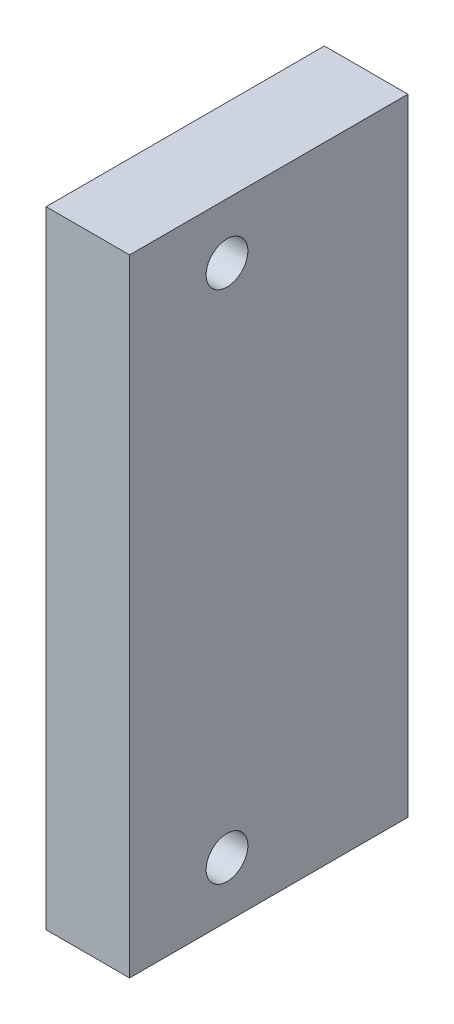
from build123d import *

# Parameters (mm, degrees)
SKETCH1_W           = 6
SKETCH1_H           = 45
BOSS_EXTRUDE1_DEPTH = 20
SKETCH2_R           = 1.5
CUT_EXTRUDE2_DEPTH  = 7


with BuildPart() as part:
    # Sketch1 → Boss-Extrude1 (new body)
    with BuildSketch(Plane.XY):
        with Locations((-10, 0)):
            Rectangle(SKETCH1_W, SKETCH1_H)
    extrude(amount=BOSS_EXTRUDE1_DEPTH)

    # Sketch2 → Cut-Extrude2 (cut, through all)
    with BuildSketch(Plane.ZY.offset(13)):
        with Locations((13, -18.5)):
            Circle(SKETCH2_R)
        with Locations((13, 18.5)):
            Circle(SKETCH2_R)
    extrude(amount=-CUT_EXTRUDE2_DEPTH, mode=Mode.SUBTRACT)


solid = part.part
